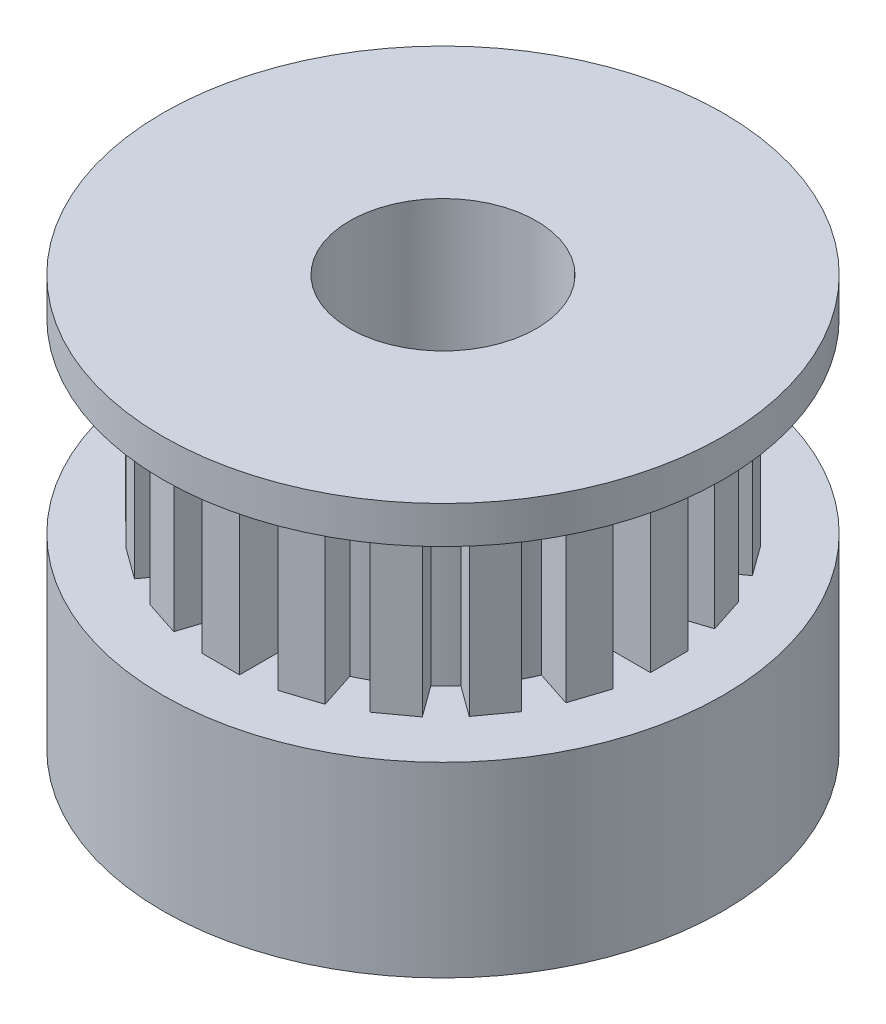
from build123d import *

# Parameters (mm, degrees)
IZIM1_R                     = 7.5
Y_KSEKLIK_EKSTR_ZYON1_DEPTH = 5
IZIM6_R                     = 5
Y_KSEKLIK_EKSTR_ZYON5_DEPTH = 5
Y_KSEKLIK_EKSTR_ZYON6_DEPTH = 7
DAIRESEL_KAPLAMA2_COUNT     = 20
IZIM8_R                     = 7.5
Y_KSEKLIK_EKSTR_ZYON7_DEPTH = 1
IZIM9_R                     = 2.5
KES_EKSTR_ZYON2_DEPTH       = 21
IZIM10_R                    = 1.2
KES_EKSTR_ZYON3_DEPTH       = 21


with BuildPart() as part:
    # Çizim1 → Yükseklik-Ekstrüzyon1 (new body)
    with BuildSketch(Plane(origin=(0, 0, 0), x_dir=(1, 0, 0), z_dir=(0, 1, 0))):
        Circle(IZIM1_R)
    extrude(amount=Y_KSEKLIK_EKSTR_ZYON1_DEPTH)

    # Çizim6 → Yükseklik-Ekstrüzyon5 (add)
    with BuildSketch(Plane(origin=(0, 5, 0), x_dir=(1, 0, 0), z_dir=(0, 1, 0))):
        Circle(IZIM6_R)
    extrude(amount=Y_KSEKLIK_EKSTR_ZYON5_DEPTH)

    # Çizim7 → Yükseklik-Ekstrüzyon6 (add)
    with BuildSketch(Plane(origin=(0, 10, 0), x_dir=(1, 0, 0), z_dir=(0, 1, 0))):
        with BuildLine():
            Line((0, 6), (0, 5))
            ThreePointArc((0, 5), (0.223628846, 4.99499651), (0.446810123, 4.979996056))
            Line((0.446810123, 4.979996056), (0.446810123, 6))
            Line((0.446810123, 6), (0, 6))
        make_face()
        with BuildLine():
            ThreePointArc((-0.553189877, 4.969303871), (-0.277020438, 4.99232007), (0, 5))
            Line((0, 5), (0, 6))
            Line((0, 6), (-0.553189877, 6))
            Line((-0.553189877, 6), (-0.553189877, 4.969303871))
        make_face()
    y_kseklik_ekstr_zyon6 = extrude(amount=-Y_KSEKLIK_EKSTR_ZYON6_DEPTH)

    # Dairesel Kaplama2: Yükseklik-Ekstrüzyon6 ×20 about axis
    dairesel_kaplama2_axis = Axis((0, 0, 0), (0, 1, 0))
    for i in range(1, DAIRESEL_KAPLAMA2_COUNT):
        add(y_kseklik_ekstr_zyon6.rotate(dairesel_kaplama2_axis, i * 360 / DAIRESEL_KAPLAMA2_COUNT))

    # Çizim8 → Yükseklik-Ekstrüzyon7 (add)
    with BuildSketch(Plane(origin=(0, 10, 0), x_dir=(1, 0, 0), z_dir=(0, 1, 0))):
        Circle(IZIM8_R)
    extrude(amount=Y_KSEKLIK_EKSTR_ZYON7_DEPTH)

    # Çizim9 → Kes-Ekstrüzyon2 (cut)
    with BuildSketch(Plane(origin=(0, 11, 0), x_dir=(1, 0, 0), z_dir=(0, 1, 0))):
        Circle(IZIM9_R)
    extrude(amount=-KES_EKSTR_ZYON2_DEPTH, mode=Mode.SUBTRACT)

    # Çizim10 → Kes-Ekstrüzyon3 (cut)
    with BuildSketch(Plane(origin=(0, 0, 0), x_dir=(0, 0, -1), z_dir=(1, 0, 0))):
        with Locations((0, 2.361227205)):
            Circle(IZIM10_R)
    extrude(amount=-KES_EKSTR_ZYON3_DEPTH, mode=Mode.SUBTRACT)


solid = part.part
